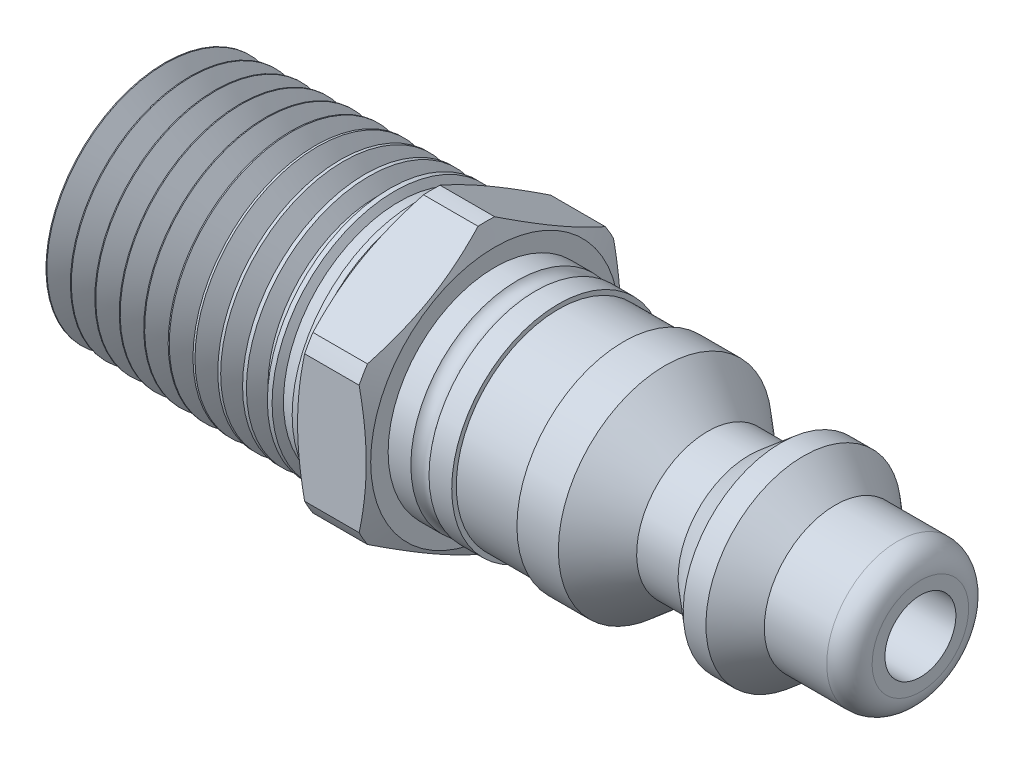
from build123d import *

# Parameters (mm, degrees)
SKETCH6_W      = 16.950500326
SKETCH6_H      = 13.781908613
EXTRUDE1_DEPTH = 3.99736
FILLET1_R      = 1.27


with BuildPart() as part:
    # Sketch1 → Revolve1 (revolve)
    with BuildSketch(Plane.XY):
        Polygon((0, 0), (0, 5.446572654), (0.025429996, 5.493979528), (0.64160868, 6.642666473), (0.695379235, 6.644346887), (1.382081969, 5.53637702), (1.435852524, 5.538057434), (2.052031208, 6.686744379), (2.105801763, 6.688424793), (2.792504496, 5.580454927), (2.846275051, 5.582135341), (3.462453735, 6.730822286), (3.51622429, 6.7325027), (4.202927024, 5.624532834), (4.256697579, 5.626213248), (4.872876263, 6.774900193), (4.926646818, 6.776580606), (5.613349551, 5.66861074), (5.667120106, 5.670291154), (6.28329879, 6.818978099), (6.337069345, 6.820658513), (7.023772079, 5.712688647), (7.077542634, 5.714369061), (7.693721318, 6.863056006), (7.747491873, 6.86473642), (8.434194606, 5.756766554), (8.487965161, 5.758446968), (9.104143845, 6.907133913), (9.1579144, 6.908814326), (9.844617134, 5.80084446), (9.898387689, 5.802524874), (10.514566373, 6.951211819), (10.568336928, 6.952892233), (11.255039661, 5.844922367), (11.308810216, 5.846602781), (11.9249889, 6.995289726), (11.978759455, 6.99697014), (12.665462189, 5.889000274), (12.719232744, 5.890680687), (13.335411428, 7.039367633), (13.389181983, 7.041048046), (14.075884716, 5.93307818), (14.129655271, 5.934758594), (14.745833955, 7.083445539), (14.79960451, 7.085125953), (15.486307244, 5.977156087), (15.540077799, 5.978836501), (16.156256483, 7.127523446), (16.210027038, 7.12920386), (16.896729771, 6.021233994), (16.950500326, 6.022914407), (16.950500326, 0), align=None)
    revolve(axis=Axis((0, 0, 0), (-1, 0, 0)))

    # Sketch5 → Cut-Revolve2 (revolve, cut)
    with BuildSketch(Plane.XY):
        Polygon((15.10284, 0), (15.10284, 7.094602536), (16.950500326, 7.152344806), (16.950500326, 0), align=None)
    revolve(axis=Axis((0, 0, 0), (-1, 0, 0)), mode=Mode.SUBTRACT)

    # Sketch6 → Cut-Revolve3 (revolve, cut)
    with BuildSketch(Plane.XY):
        with Locations((8.475250163, 13.748954307)):
            Rectangle(SKETCH6_W, SKETCH6_H)
    revolve(axis=Axis((0, 0, 0), (1, 0, 0)), mode=Mode.SUBTRACT)

    # Sketch7 → Revolve2 (revolve)
    with BuildSketch(Plane.XY):
        Polygon((10.2108, 5.446572654), (15.10284, 6.858), (15.10284, 5.446572654), align=None)
    revolve(axis=Axis((0, 0, 0), (1, 0, 0)))

    # Sketch8 → Extrude1 (add)
    with BuildSketch(Plane(origin=(15.10284, 0, 0), x_dir=(0, 0, -1), z_dir=(1, 0, 0))):
        Polygon((0, 8.212230229), (-7.112, 4.106115114), (-7.112, -4.106115114), (0, -8.212230229), (7.112, -4.106115114), (7.112, 4.106115114), align=None)
    extrude(amount=EXTRUDE1_DEPTH)

    # Sketch9 → Cut-Revolve4 (revolve, cut)
    with BuildSketch(Plane.XY):
        Polygon((19.1002, 6.942230229), (18.626431419, 7.958230229), (15.576608581, 7.958230229), (15.10284, 6.942230229), (15.10284, 8.212230229), (19.1002, 8.212230229), align=None)
    revolve(axis=Axis((0, 0, 0), (1, 0, 0)), mode=Mode.SUBTRACT)

    # Sketch10 → Revolve3 (revolve)
    with BuildSketch(Plane.XY):
        with BuildLine():
            Line((19.1002, 0), (42.9, 0))
            Line((42.9, 0), (42.9, 3.96875))
            Line((42.9, 3.96875), (38.1375, 3.96875))
            Line((38.1375, 3.96875), (36.362408616, 5.458228526))
            Line((36.362408616, 5.458228526), (35.092408616, 5.458228526))
            Line((35.092408616, 5.458228526), (33.317317232, 3.96875))
            Line((33.317317232, 3.96875), (31.0001, 3.96875))
            Line((31.0001, 3.96875), (28.619597791, 5.966228526))
            Line((28.619597791, 5.966228526), (26.302380559, 5.966228526))
            Line((26.302380559, 5.966228526), (26.302380559, 5.712228526))
            Line((26.302380559, 5.712228526), (22.6562, 5.712228526))
            Line((22.6562, 5.712228526), (22.6562, 5.966228526))
            Line((22.6562, 5.966228526), (21.3862, 5.966228526))
            ThreePointArc((21.3862, 5.966228526), (20.8782, 5.712228526), (20.3702, 5.966228526))
            Line((20.3702, 5.966228526), (19.1002, 5.966228526))
            Line((19.1002, 5.966228526), (19.1002, 0))
        make_face()
    revolve(axis=Axis((0, 0, 0), (-1, 0, 0)))

    # Fillet1
    fillet1_edges = [part.edges().sort_by_distance(p)[0] for p in [
        (42.9, -3.96875, 0),
    ]]
    fillet(fillet1_edges, radius=FILLET1_R)

    # Sketch11 → Cut-Revolve5 (revolve, cut)
    with BuildSketch(Plane.XY):
        Polygon((15.10284, 4.6228), (19.1002, 1.984375), (42.9, 1.984375), (42.9, 0), (10.2108, 0), (0, 0), (0, 4.6228), align=None)
    revolve(axis=Axis((0, 0, 0), (-1, 0, 0)), mode=Mode.SUBTRACT)


solid = part.part
